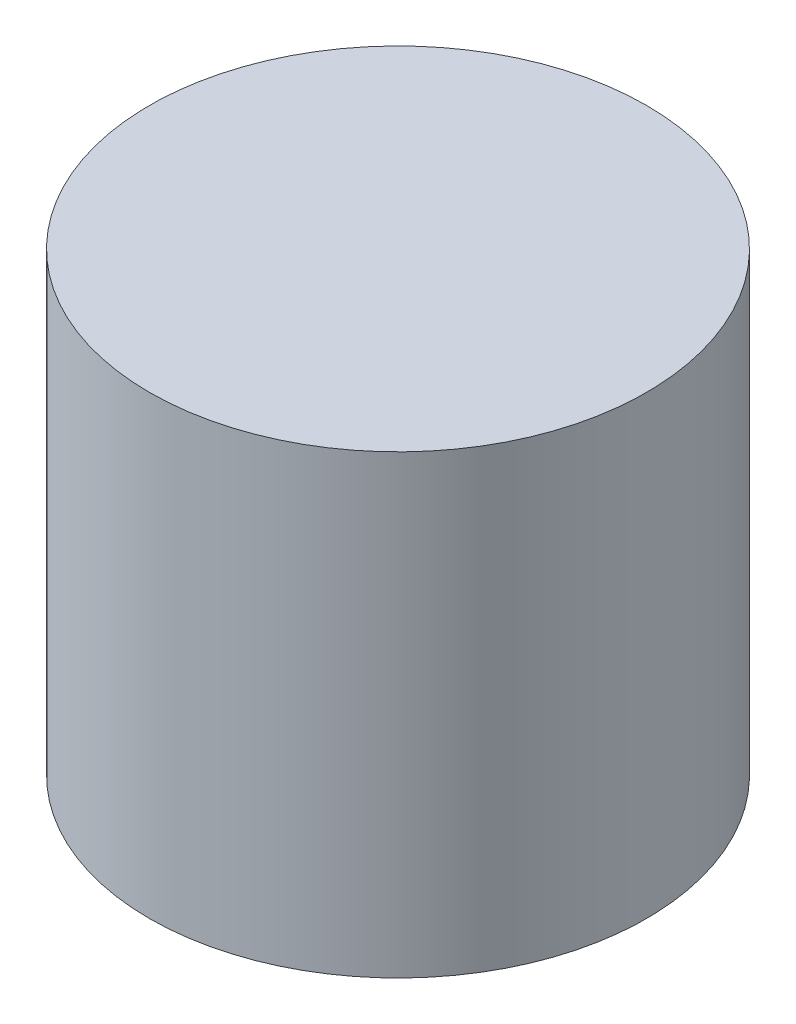
from build123d import *

# Parameters (mm, degrees)
SKETCH1_R           = 6
BOSS_EXTRUDE1_DEPTH = 11


with BuildPart() as part:
    # Sketch1 → Boss-Extrude1 (new body)
    with BuildSketch(Plane(origin=(0, 0, 0), x_dir=(1, 0, 0), z_dir=(0, 1, 0))):
        Circle(SKETCH1_R)
    extrude(amount=BOSS_EXTRUDE1_DEPTH)


solid = part.part
